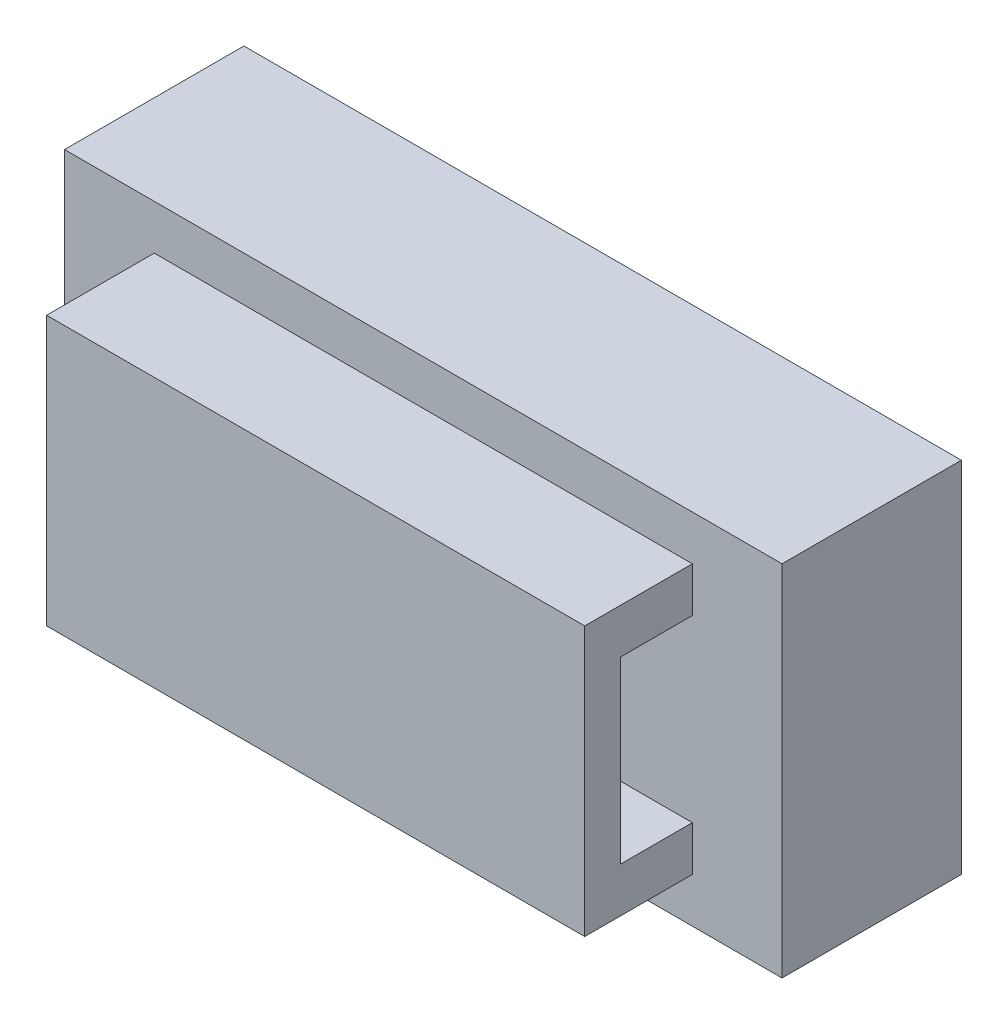
from build123d import *

# Parameters (mm, degrees)
SKETCH_1_W          = 40
SKETCH_1_H          = 20
EXTRUDE_1_DEPTH     = 10
SKETCH_2_W          = 30
SKETCH_2_H          = 15
EXTRUDE_2_DEPTH     = 6
SKETCH_3_W          = 4
SKETCH_3_H          = 10
CUT_EXTRUDE_1_DEPTH = 40


with BuildPart() as part:
    # 草图1 → 凸台-拉伸1 (new body)
    with BuildSketch(Plane.XY):
        Rectangle(SKETCH_1_W, SKETCH_1_H)
    extrude(amount=EXTRUDE_1_DEPTH)

    # 草图2 → 凸台-拉伸2 (add)
    with BuildSketch(Plane.XY.offset(10)):
        Rectangle(SKETCH_2_W, SKETCH_2_H)
    extrude(amount=EXTRUDE_2_DEPTH)

    # 草图3 → 切除-拉伸1 (cut)
    with BuildSketch(Plane(origin=(15, 0, 0), x_dir=(0, 0, -1), z_dir=(1, 0, 0))):
        with Locations((-12, 0)):
            Rectangle(SKETCH_3_W, SKETCH_3_H)
    extrude(amount=-CUT_EXTRUDE_1_DEPTH, mode=Mode.SUBTRACT)


solid = part.part
